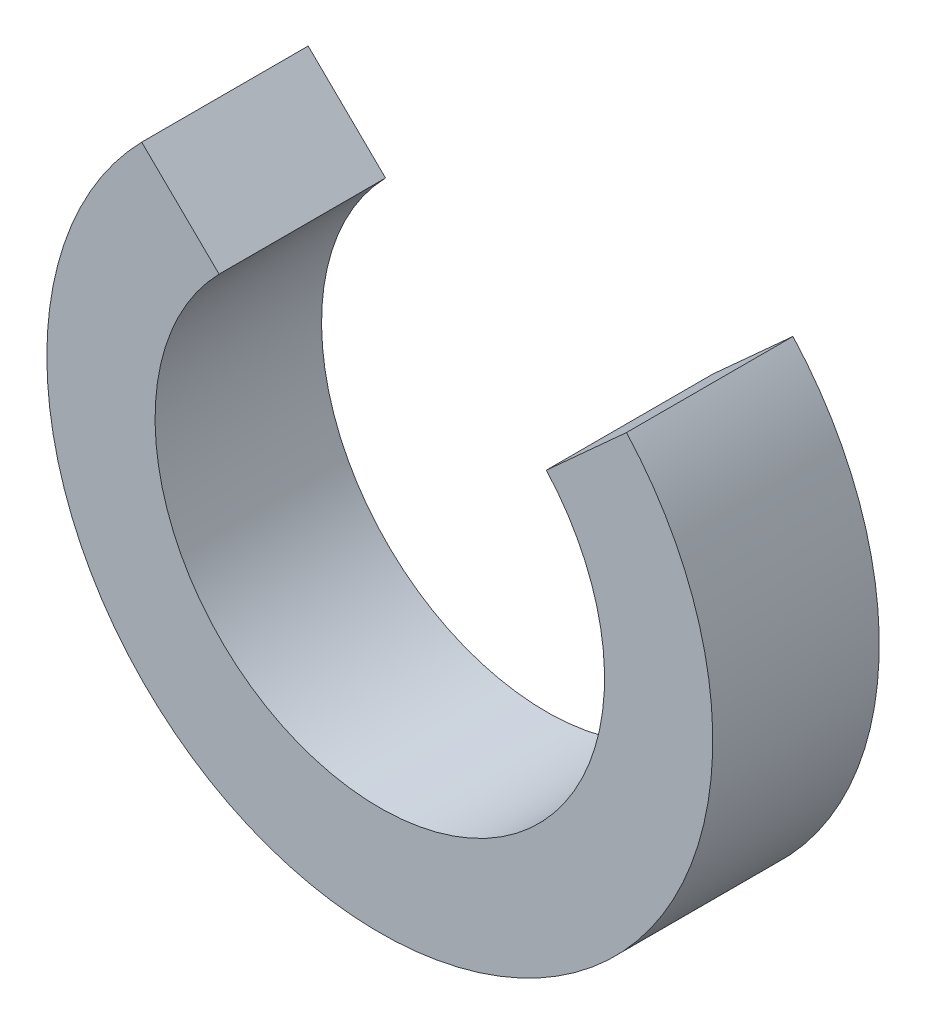
from build123d import *

# Parameters (mm, degrees)
SKETCH1_R               = 40
SKETCH1_R_2             = 27
BOSS_EXTRUDE1_DEPTH     = 20
CUT_EXTRUDE4_DEPTH      = 21
CUT_EXTRUDE4_DEPTH_BACK = 1


with BuildPart() as part:
    # Sketch1 → Boss-Extrude1 (new body)
    with BuildSketch(Plane.XY):
        Circle(SKETCH1_R)
        Circle(SKETCH1_R_2, mode=Mode.SUBTRACT)
    extrude(amount=BOSS_EXTRUDE1_DEPTH)

    # Sketch2 → Cut-Extrude4 (cut, two sides)
    with BuildSketch(Plane.XY) as cut_extrude4_sk:
        with BuildLine():
            Line((-28.606436337, 27.95839409), (-19.309344528, 18.871916011))
            ThreePointArc((-19.309344528, 18.871916011), (-11.064957407, 24.628575224), (-1.28591011, 26.969361045))
            ThreePointArc((-1.28591011, 26.969361045), (10.34888974, 24.937932576), (20.003413651, 18.134592422))
            Line((20.003413651, 18.134592422), (29.63468689, 26.866062848))
            ThreePointArc((29.63468689, 26.866062848), (0.941903369, 39.988908688), (-28.33691177, 28.231532571))
            ThreePointArc((-28.33691177, 28.231532571), (-28.472001591, 28.095286534), (-28.606436337, 27.95839409))
        make_face()
    extrude(amount=CUT_EXTRUDE4_DEPTH, mode=Mode.SUBTRACT)
    extrude(cut_extrude4_sk.sketch, amount=-CUT_EXTRUDE4_DEPTH_BACK, mode=Mode.SUBTRACT)


solid = part.part
